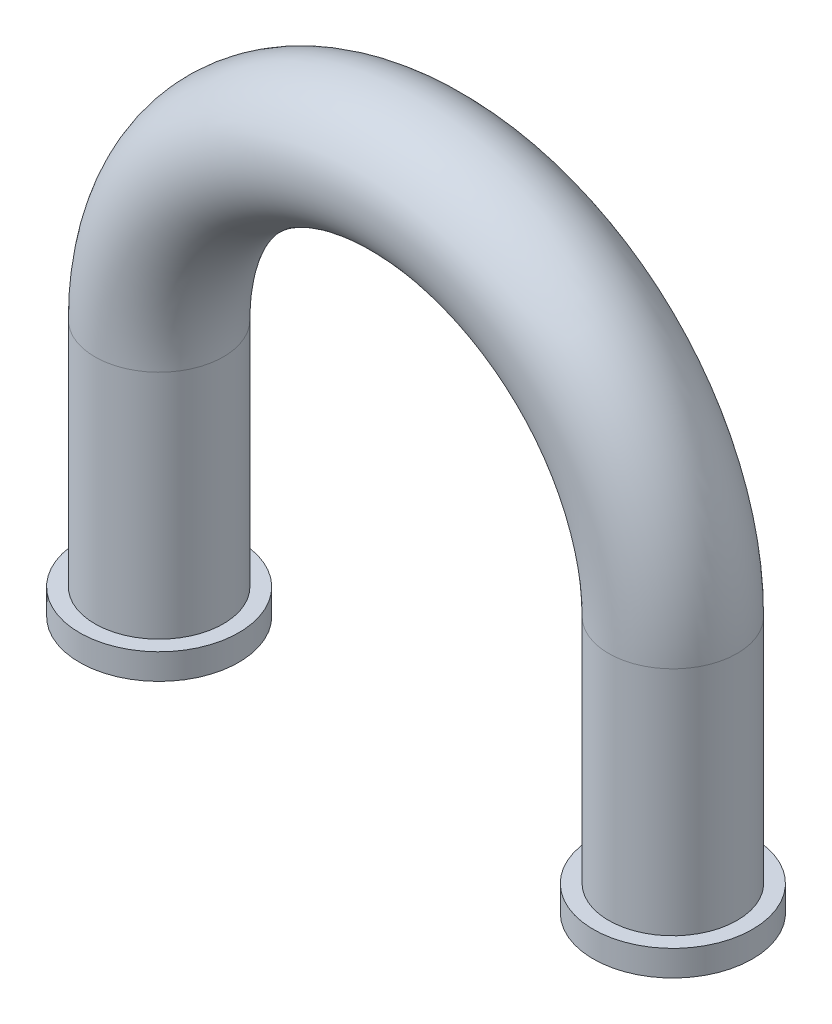
from build123d import *

# Parameters (mm, degrees)
IZIM3_R   = 0.25
IZIM3_R_2 = 0.2
IZIM5_R   = 0.31
IZIM5_R_2 = 0.21


with BuildPart() as part:
    # Süpür-İnce1: sweep along a path in Çizim1
    with BuildLine(Plane.XY) as s_p_r_nce1_path:
        Line((1, -1), (1, 0))
        ThreePointArc((1, 0), (0.707106781, 0.707106781), (0, 1))
    # Çizim3 → Süpür-İnce1 (sweep)
    with BuildSketch(Plane(origin=(0, 0, 0), x_dir=(0, 0, -1), z_dir=(1, 0, 0))):
        with Locations((0, 1)):
            Circle(IZIM3_R)
        with Locations((0, 1)):
            Circle(IZIM3_R_2, mode=Mode.SUBTRACT)
    sweep(path=s_p_r_nce1_path.line)

    # Süpür-İnce3: sweep along a path in Çizim6
    with BuildLine(Plane.XY) as s_p_r_nce3_path:
        Line((1, -1), (1, -0.9))
    # Çizim5 → Süpür-İnce3 (sweep)
    with BuildSketch(Plane(origin=(0, -1, 0), x_dir=(-1, 0, 0), z_dir=(0, -1, 0))):
        with Locations((-1, 0)):
            Circle(IZIM5_R)
        with Locations((-1, 0)):
            Circle(IZIM5_R_2, mode=Mode.SUBTRACT)
    sweep(path=s_p_r_nce3_path.line)

    # Aynalama1: part across plane


with BuildPart() as part_1:
    add(part.part)
    add(part.part.mirror(Plane(origin=(0, 0, 0), x_dir=(0, 0, 1), z_dir=(1, 0, 0))))


solid = part_1.part
